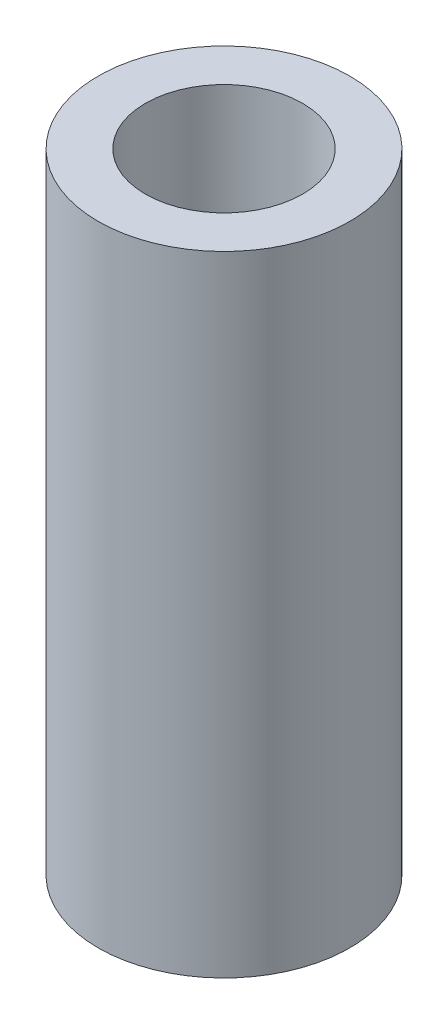
from build123d import *

# Parameters (mm, degrees)
CROQUIS1_R              = 4
CROQUIS1_R_2            = 2.5
SALIENTE_EXTRUIR1_DEPTH = 20


with BuildPart() as part:
    # Croquis1 → Saliente-Extruir1 (new body)
    with BuildSketch(Plane(origin=(0, 0, 0), x_dir=(1, 0, 0), z_dir=(0, 1, 0))):
        Circle(CROQUIS1_R)
        Circle(CROQUIS1_R_2, mode=Mode.SUBTRACT)
    extrude(amount=SALIENTE_EXTRUIR1_DEPTH)


solid = part.part
